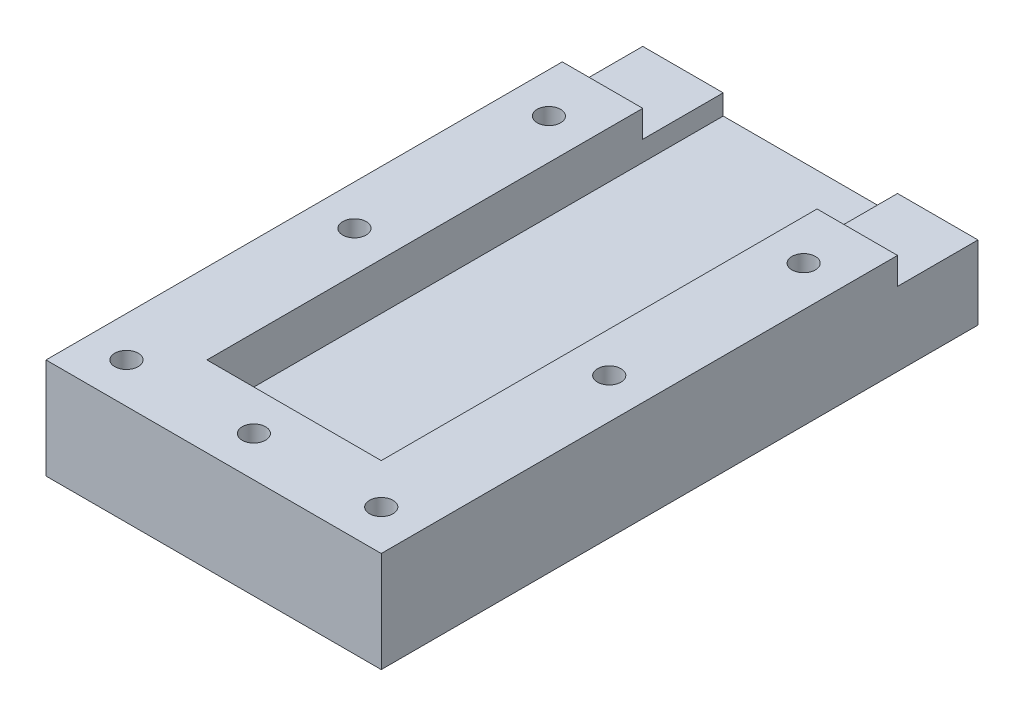
from build123d import *

# Parameters (mm, degrees)
SKETCH_1_W          = 50
SKETCH_1_H          = 30
EXTRUDE_1_DEPTH     = 89
SKETCH_2_W          = 26
SKETCH_2_H          = 14
CUT_EXTRUDE_1_DEPTH = 77
SKETCH_5_W          = 12
SKETCH_5_H          = 8
CUT_EXTRUDE_4_DEPTH = 98.928545379
SKETCH_6_W          = 12
SKETCH_6_H          = 8
CUT_EXTRUDE_5_DEPTH = 98.928545379
SKETCH_7_R          = 1.75
CUT_EXTRUDE_6_DEPTH = 98.190534519


with BuildPart() as part:
    # ｽｹｯﾁ1 → ﾎﾞｽ - 押し出し1 (new body)
    with BuildSketch(Plane.XY):
        Rectangle(SKETCH_1_W, SKETCH_1_H)
    extrude(amount=EXTRUDE_1_DEPTH)

    # ｽｹｯﾁ2 → ｶｯﾄ - 押し出し1 (cut)
    with BuildSketch(Plane(origin=(0, 0, 0), x_dir=(-1, 0, 0), z_dir=(0, 0, -1))):
        Rectangle(SKETCH_2_W, SKETCH_2_H)
    extrude(amount=-CUT_EXTRUDE_1_DEPTH, mode=Mode.SUBTRACT)

    # ｽｹｯﾁ5 → ｶｯﾄ - 押し出し4 (cut, through all)
    with BuildSketch(Plane.ZY.offset(-13)):
        with Locations((6, 0)):
            Rectangle(SKETCH_5_W, SKETCH_5_H)
    extrude(amount=-CUT_EXTRUDE_4_DEPTH, mode=Mode.SUBTRACT)

    # ｽｹｯﾁ6 → ｶｯﾄ - 押し出し5 (cut, through all)
    with BuildSketch(Plane(origin=(-13, 0, 0), x_dir=(0, 0, -1), z_dir=(1, 0, 0))):
        with Locations((-6, 0)):
            Rectangle(SKETCH_6_W, SKETCH_6_H)
    extrude(amount=-CUT_EXTRUDE_5_DEPTH, mode=Mode.SUBTRACT)

    # ｽｹｯﾁ7 → ｶｯﾄ - 押し出し6 (cut, through all)
    with BuildSketch(Plane(origin=(0, 15, 0), x_dir=(1, 0, 0), z_dir=(0, 1, 0))):
        with Locations(Location((19, -20, 0), (0, 0, 270))):
            Circle(SKETCH_7_R)
        with Locations(Location((19, -49, 0), (0, 0, 270))):
            Circle(SKETCH_7_R)
        with Locations(Location((19, -83, 0), (0, 0, 270))):
            Circle(SKETCH_7_R)
        with Locations(Location((0, -83, 0), (0, 0, 270))):
            Circle(SKETCH_7_R)
        with Locations(Location((-19, -83, 0), (0, 0, 270))):
            Circle(SKETCH_7_R)
        with Locations(Location((-19, -49, 0), (0, 0, 270))):
            Circle(SKETCH_7_R)
        with Locations(Location((-19, -20, 0), (0, 0, 270))):
            Circle(SKETCH_7_R)
    extrude(amount=-CUT_EXTRUDE_6_DEPTH, mode=Mode.SUBTRACT)

    # Surface Cut 1
    split(bisect_by=Plane(origin=(0, 0, 0), x_dir=(-1, 0, 0), z_dir=(0, -1, 0)), keep=Keep.TOP)


solid = part.part
